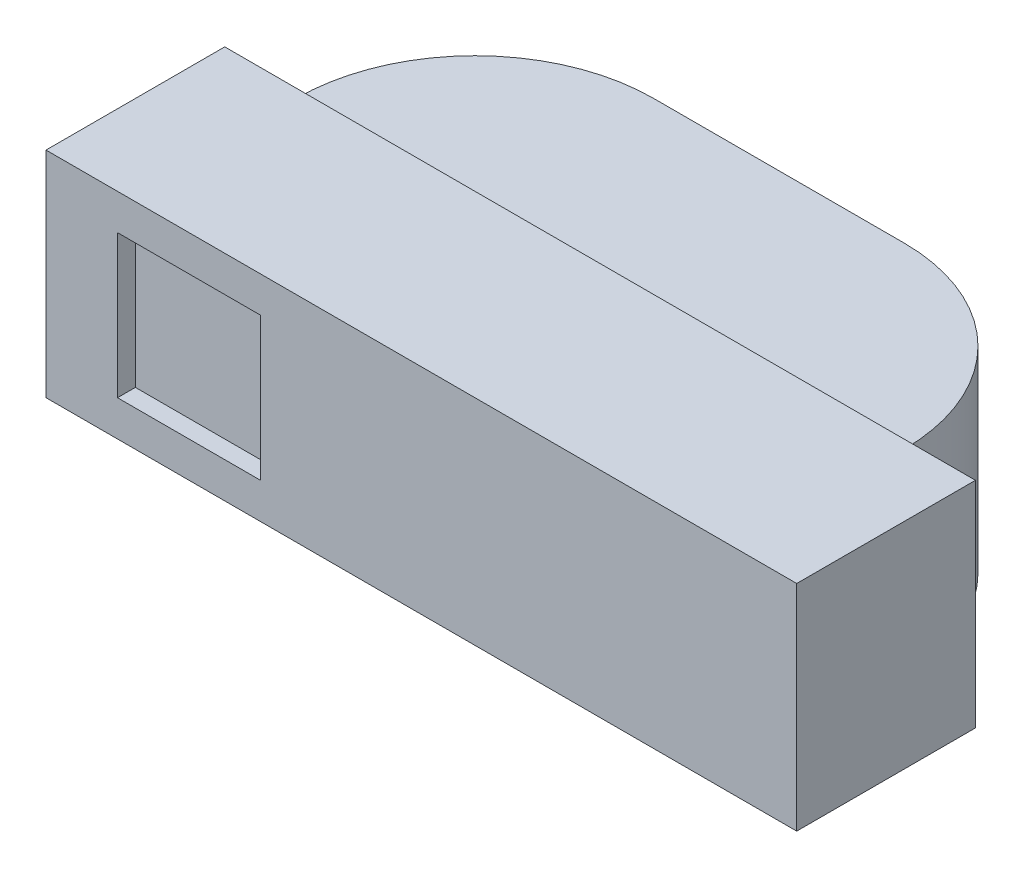
from build123d import *

# Parameters (mm, degrees)
BOSS_EXTRUDE1_DEPTH = 0.6
SKETCH2_W           = 2.1
SKETCH2_H           = 0.025
CUT_EXTRUDE1_DEPTH  = 0.5
SKETCH3_W           = 0.4
SKETCH3_H           = 0.4
CUT_EXTRUDE2_DEPTH  = 0.05


with BuildPart() as part:
    # Sketch1 → Boss-Extrude1 (new body)
    with BuildSketch(Plane(origin=(0, 0, 0), x_dir=(1, 0, 0), z_dir=(0, 1, 0))):
        with BuildLine():
            Line((-1.05, -0.5), (1.05, -0.5))
            Line((1.05, -0.5), (1.05, 0))
            Line((1.05, 0), (0.85, 0))
            ThreePointArc((0.85, 0), (0.703553391, 0.353553391), (0.35, 0.5))
            Line((0.35, 0.5), (-0.35, 0.5))
            ThreePointArc((-0.35, 0.5), (-0.703553391, 0.353553391), (-0.85, 0))
            Line((-0.85, 0), (-1.05, 0))
            Line((-1.05, 0), (-1.05, -0.5))
        make_face()
    extrude(amount=BOSS_EXTRUDE1_DEPTH)

    # Sketch2 → Cut-Extrude1 (cut)
    with BuildSketch(Plane(origin=(0, 0, -0.5), x_dir=(-1, 0, 0), z_dir=(0, 0, -1))):
        with Locations((0, 0.5875)):
            Rectangle(SKETCH2_W, SKETCH2_H)
        with Locations((0, 0.0125)):
            Rectangle(SKETCH2_W, SKETCH2_H)
    extrude(amount=-CUT_EXTRUDE1_DEPTH, mode=Mode.SUBTRACT)

    # Sketch3 → Cut-Extrude2 (cut)
    with BuildSketch(Plane.XY.offset(0.5)):
        with Locations((-0.65, 0.3)):
            Rectangle(SKETCH3_W, SKETCH3_H)
    extrude(amount=-CUT_EXTRUDE2_DEPTH, mode=Mode.SUBTRACT)


solid = part.part
